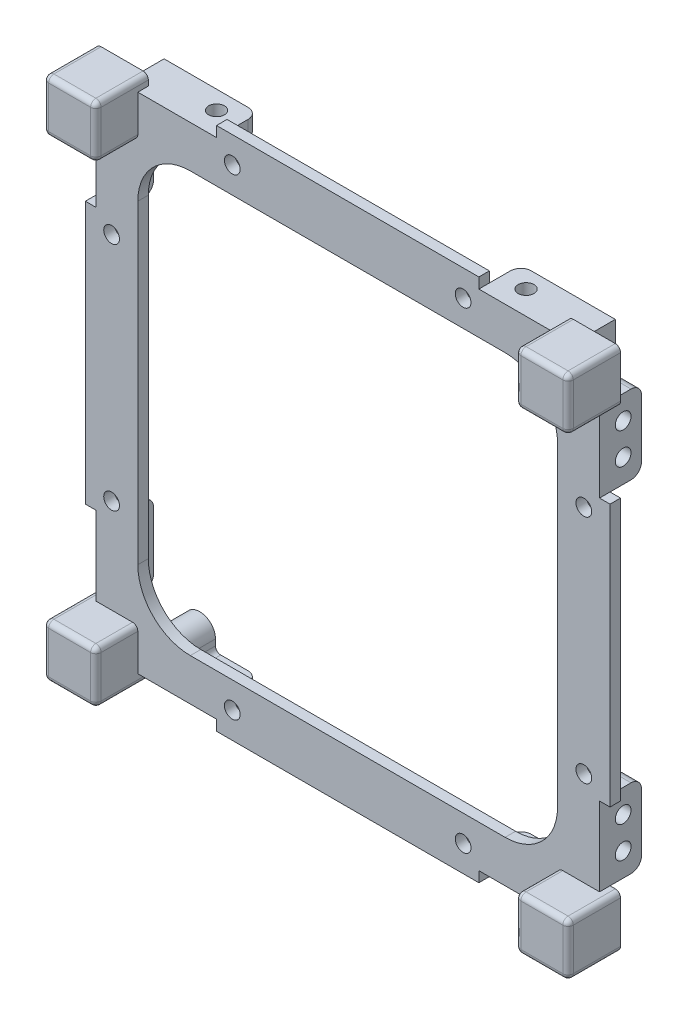
from build123d import *

# Parameters (mm, degrees)
SKETCH1_R               = 1.5
BOSS_EXTRUDE1_DEPTH     = 2
BOSS_EXTRUDE3_DEPTH     = 8
FILLET2_R               = 1
SKETCH6_R               = 1.5
SKETCH6_W               = 3
SKETCH6_H               = 15
BOSS_EXTRUDE5_DEPTH     = 6
FILLET3_R               = 2
SKETCH7_R               = 1.5
CUT_EXTRUDE1_DEPTH      = 51
CUT_EXTRUDE1_DEPTH_BACK = 51
SKETCH8_R               = 1.5
CUT_EXTRUDE2_DEPTH      = 51
CUT_EXTRUDE2_DEPTH_BACK = 51


with BuildPart() as part:
    # Sketch1 → Boss-Extrude1 (new body)
    with BuildSketch(Plane.XY):
        with BuildLine():
            Line((-50, 40), (-48, 40))
            Line((-48, 40), (-48, 25))
            Line((-48, 25), (-50, 25))
            Line((-50, 25), (-50, -25))
            Line((-50, -25), (-48, -25))
            Line((-48, -25), (-48, -40))
            Line((-48, -40), (-50, -40))
            Line((-50, -40), (-50, -49))
            ThreePointArc((-50, -49), (-49.707106781, -49.707106781), (-49, -50))
            Line((-49, -50), (-40, -50))
            Line((-40, -50), (-40, -48))
            Line((-40, -48), (-25, -48))
            Line((-25, -48), (-25, -50))
            Line((-25, -50), (25, -50))
            Line((25, -50), (25, -48))
            Line((25, -48), (40, -48))
            Line((40, -48), (40, -50))
            Line((40, -50), (49, -50))
            ThreePointArc((49, -50), (49.707106781, -49.707106781), (50, -49))
            Line((50, -49), (50, -40))
            Line((50, -40), (48, -40))
            Line((48, -40), (48, -25))
            Line((48, -25), (50, -25))
            Line((50, -25), (50, 25))
            Line((50, 25), (48, 25))
            Line((48, 25), (48, 40))
            Line((48, 40), (50, 40))
            Line((50, 40), (50, 49))
            ThreePointArc((50, 49), (49.707106781, 49.707106781), (49, 50))
            Line((49, 50), (40, 50))
            Line((40, 50), (40, 48))
            Line((40, 48), (25, 48))
            Line((25, 48), (25, 50))
            Line((25, 50), (-25, 50))
            Line((-25, 50), (-25, 48))
            Line((-25, 48), (-40, 48))
            Line((-40, 48), (-40, 50))
            Line((-40, 50), (-49, 50))
            ThreePointArc((-49, 50), (-49.707106781, 49.707106781), (-50, 49))
            Line((-50, 49), (-50, 40))
        make_face()
        with Locations((-45, 22)):
            Circle(SKETCH1_R, mode=Mode.SUBTRACT)
        with Locations((-22, 45)):
            Circle(SKETCH1_R, mode=Mode.SUBTRACT)
        with Locations((22, 45)):
            Circle(SKETCH1_R, mode=Mode.SUBTRACT)
        with Locations((45, 22)):
            Circle(SKETCH1_R, mode=Mode.SUBTRACT)
        with Locations((45, -22)):
            Circle(SKETCH1_R, mode=Mode.SUBTRACT)
        with Locations((22, -45)):
            Circle(SKETCH1_R, mode=Mode.SUBTRACT)
        with Locations((-22, -45)):
            Circle(SKETCH1_R, mode=Mode.SUBTRACT)
        with Locations((-45, -22)):
            Circle(SKETCH1_R, mode=Mode.SUBTRACT)
        with BuildLine():
            Line((-30, -40), (30, -40))
            ThreePointArc((30, -40), (37.071067812, -37.071067812), (40, -30))
            Line((40, -30), (40, 30))
            ThreePointArc((40, 30), (37.071067812, 37.071067812), (30, 40))
            Line((30, 40), (-30, 40))
            ThreePointArc((-30, 40), (-37.071067812, 37.071067812), (-40, 30))
            Line((-40, 30), (-40, -30))
            ThreePointArc((-40, -30), (-37.071067812, -37.071067812), (-30, -40))
        make_face(mode=Mode.SUBTRACT)
    extrude(amount=BOSS_EXTRUDE1_DEPTH)

    # Sketch2 → Boss-Extrude3 (add)
    with BuildSketch(Plane.XY.offset(2)):
        with BuildLine():
            Line((-49, 50), (-40, 50))
            Line((-40, 50), (-40, 40))
            Line((-40, 40), (-50, 40))
            Line((-50, 40), (-50, 49))
            ThreePointArc((-50, 49), (-49.707106781, 49.707106781), (-49, 50))
        make_face()
        with BuildLine():
            Line((40, 50), (40, 40))
            Line((40, 40), (50, 40))
            Line((50, 40), (50, 49))
            ThreePointArc((50, 49), (49.707106781, 49.707106781), (49, 50))
            Line((49, 50), (40, 50))
        make_face()
        with BuildLine():
            Line((49, -50), (40, -50))
            Line((40, -50), (40, -40))
            Line((40, -40), (50, -40))
            Line((50, -40), (50, -49))
            ThreePointArc((50, -49), (49.707106781, -49.707106781), (49, -50))
        make_face()
        with BuildLine():
            Line((-40, -50), (-40, -40))
            Line((-40, -40), (-50, -40))
            Line((-50, -40), (-50, -49))
            ThreePointArc((-50, -49), (-49.707106781, -49.707106781), (-49, -50))
            Line((-49, -50), (-40, -50))
        make_face()
    extrude(amount=BOSS_EXTRUDE3_DEPTH)

    # Fillet2
    fillet2_edges = [part.edges().sort_by_distance(p)[0] for p in [
        (-40, 40, 6),
        (-40, 45, 10),
        (-44.5, 50, 10),
        (-49.707106781, 49.707106781, 10),
        (-50, 44.5, 10),
        (-45, 40, 10),
        (40, 40, 6),
        (50, 44.5, 10),
        (49.707106781, 49.707106781, 10),
        (44.5, 50, 10),
        (40, 45, 10),
        (45, 40, 10),
        (40, -40, 6),
        (40, -45, 10),
        (44.5, -50, 10),
        (49.707106781, -49.707106781, 10),
        (50, -44.5, 10),
        (45, -40, 10),
        (-40, -40, 6),
        (-50, -44.5, 10),
        (-49.707106781, -49.707106781, 10),
        (-44.5, -50, 10),
        (-40, -45, 10),
        (-45, -40, 10),
        (-50, -40, 5),
        (-50, 40, 5),
        (-40, 50, 5),
        (40, 50, 5),
        (50, 40, 5),
        (50, -40, 5),
        (40, -50, 5),
        (-40, -50, 5),
    ]]
    fillet(fillet2_edges, radius=FILLET2_R)

    # Sketch6 → Boss-Extrude5 (add)
    with BuildSketch(Plane(origin=(0, 0, 0), x_dir=(-1, 0, 0), z_dir=(0, 0, -1))):
        with BuildLine():
            Line((-43, 48), (-43, 42.85))
            ThreePointArc((-43, 42.85), (-40, 39.85), (-37, 42.85))
            Line((-37, 42.85), (-37, 44))
            ThreePointArc((-37, 44), (-36.707106781, 44.707106781), (-36, 45))
            Line((-36, 45), (-25, 45))
            Line((-25, 45), (-25, 48))
            Line((-25, 48), (-43, 48))
        make_face()
        with Locations((-40, 42.85)):
            Circle(SKETCH6_R, mode=Mode.SUBTRACT)
        with BuildLine():
            Line((25, 48), (25, 45))
            Line((25, 45), (36, 45))
            ThreePointArc((36, 45), (36.707106781, 44.707106781), (37, 44))
            Line((37, 44), (37, 42.85))
            ThreePointArc((37, 42.85), (40, 39.85), (43, 42.85))
            Line((43, 42.85), (43, 48))
            Line((43, 48), (25, 48))
        make_face()
        with Locations((40, 42.85)):
            Circle(SKETCH6_R, mode=Mode.SUBTRACT)
        with BuildLine():
            Line((-40.4, -48), (-40.4, -42.85))
            ThreePointArc((-40.4, -42.85), (-37.4, -39.85), (-34.4, -42.85))
            Line((-34.4, -42.85), (-34.4, -44))
            ThreePointArc((-34.4, -44), (-34.107106781, -44.707106781), (-33.4, -45))
            Line((-33.4, -45), (-25, -45))
            Line((-25, -45), (-25, -48))
            Line((-25, -48), (-40.4, -48))
        make_face()
        with Locations((-37.4, -42.85)):
            Circle(SKETCH6_R, mode=Mode.SUBTRACT)
        with BuildLine():
            Line((25, -48), (25, -45))
            Line((25, -45), (32.2, -45))
            ThreePointArc((32.2, -45), (32.907106781, -44.707106781), (33.2, -44))
            Line((33.2, -44), (33.2, -42.85))
            ThreePointArc((33.2, -42.85), (36.2, -39.85), (39.2, -42.85))
            Line((39.2, -42.85), (39.2, -48))
            Line((39.2, -48), (25, -48))
        make_face()
        with Locations((36.2, -42.85)):
            Circle(SKETCH6_R, mode=Mode.SUBTRACT)
        with Locations((-46.5, 32.5)):
            Rectangle(SKETCH6_W, SKETCH6_H)
        with Locations((46.5, 32.5)):
            Rectangle(SKETCH6_W, SKETCH6_H)
        with Locations((-46.5, -32.5)):
            Rectangle(SKETCH6_W, SKETCH6_H)
        with Locations((46.5, -32.5)):
            Rectangle(SKETCH6_W, SKETCH6_H)
    extrude(amount=BOSS_EXTRUDE5_DEPTH)

    # Fillet3
    fillet3_edges = [part.edges().sort_by_distance(p)[0] for p in [
        (25, 46.5, -6),
        (-25, 46.5, -6),
        (25, -46.5, -6),
        (-25, -46.5, -6),
        (46.5, 25, -6),
        (46.5, 40, -6),
        (-46.5, 40, -6),
        (-46.5, 25, -6),
        (46.5, -40, -6),
        (46.5, -25, -6),
        (-46.5, -25, -6),
        (-46.5, -40, -6),
    ]]
    fillet(fillet3_edges, radius=FILLET3_R)

    # Sketch7 → Cut-Extrude1 (cut, two sides)
    with BuildSketch(Plane(origin=(0, 0, 0), x_dir=(0, 0, -1), z_dir=(1, 0, 0))) as cut_extrude1_sk:
        with Locations((2.5, 35.5)):
            Circle(SKETCH7_R)
        with Locations((2.5, 29.5)):
            Circle(SKETCH7_R)
        with Locations((2.5, -29.5)):
            Circle(SKETCH7_R)
        with Locations((2.5, -35.5)):
            Circle(SKETCH7_R)
    extrude(amount=CUT_EXTRUDE1_DEPTH, mode=Mode.SUBTRACT)
    extrude(cut_extrude1_sk.sketch, amount=-CUT_EXTRUDE1_DEPTH_BACK, mode=Mode.SUBTRACT)

    # Sketch8 → Cut-Extrude2 (cut, two sides)
    with BuildSketch(Plane(origin=(0, 0, 0), x_dir=(1, 0, 0), z_dir=(0, 1, 0))) as cut_extrude2_sk:
        with Locations((-29.5, 2.5)):
            Circle(SKETCH8_R)
        with Locations((29.5, 2.5)):
            Circle(SKETCH8_R)
    extrude(amount=CUT_EXTRUDE2_DEPTH, mode=Mode.SUBTRACT)
    extrude(cut_extrude2_sk.sketch, amount=-CUT_EXTRUDE2_DEPTH_BACK, mode=Mode.SUBTRACT)


solid = part.part
